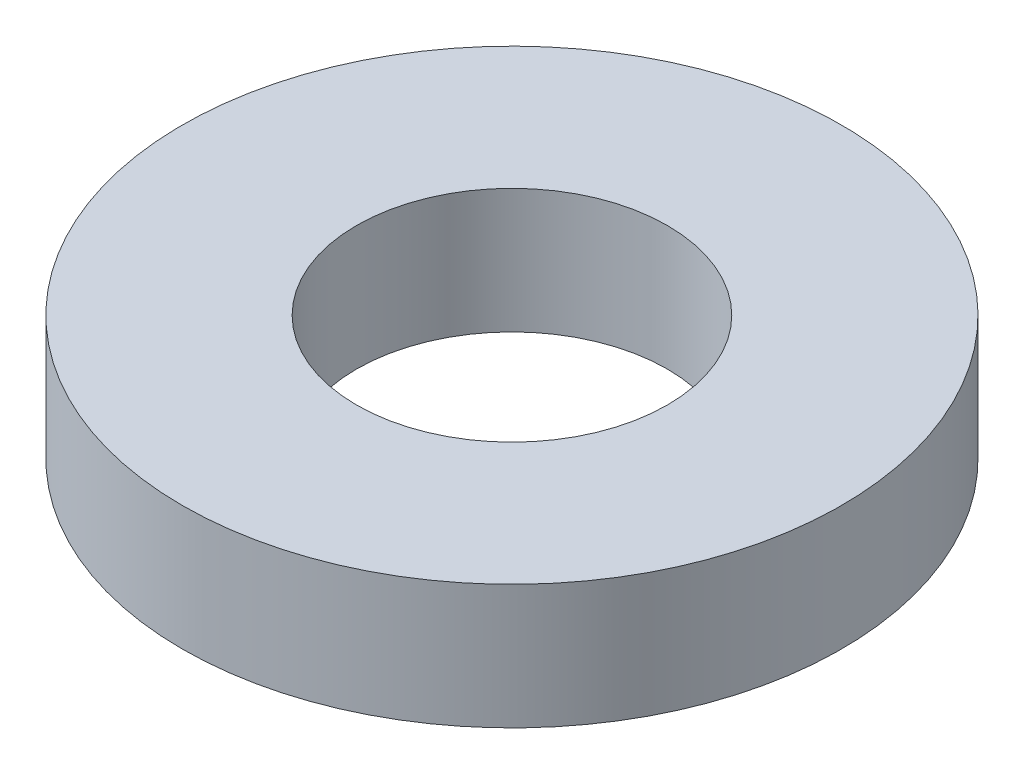
from build123d import *

# Parameters (mm, degrees)
SKETCH1_R           = 3.3655
SKETCH1_R_2         = 1.5875
BOSS_EXTRUDE1_DEPTH = 1.27


with BuildPart() as part:
    # Sketch1 → Boss-Extrude1 (new body)
    with BuildSketch(Plane(origin=(0, 0, 0), x_dir=(1, 0, 0), z_dir=(0, 1, 0))):
        Circle(SKETCH1_R)
        Circle(SKETCH1_R_2, mode=Mode.SUBTRACT)
    extrude(amount=BOSS_EXTRUDE1_DEPTH)


solid = part.part
